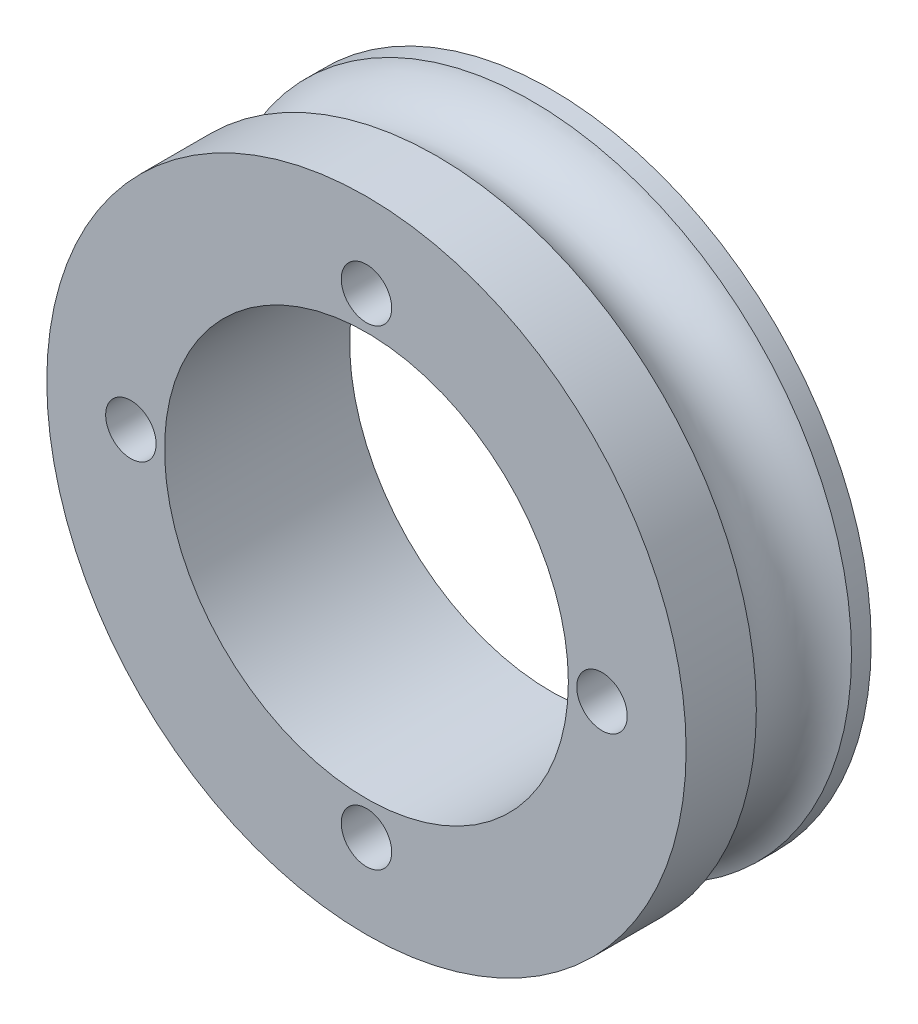
from build123d import *

# Parameters (mm, degrees)
SCHIZZO1_R                   = 19
SCHIZZO1_R_2                 = 12
SCHIZZO1_R_3                 = 1.5
ESTRUSIONE_ESTRUSIONE1_DEPTH = 11
SCHIZZO2_R                   = 3


with BuildPart() as part:
    # Schizzo1 → Estrusione-Estrusione1 (new body)
    with BuildSketch(Plane.XY):
        Circle(SCHIZZO1_R)
        Circle(SCHIZZO1_R_2, mode=Mode.SUBTRACT)
        with Locations((0, 14)):
            Circle(SCHIZZO1_R_3, mode=Mode.SUBTRACT)
        with Locations((14, 0)):
            Circle(SCHIZZO1_R_3, mode=Mode.SUBTRACT)
        with Locations((0, -14)):
            Circle(SCHIZZO1_R_3, mode=Mode.SUBTRACT)
        with Locations((-14, 0)):
            Circle(SCHIZZO1_R_3, mode=Mode.SUBTRACT)
    extrude(amount=ESTRUSIONE_ESTRUSIONE1_DEPTH)

    # Schizzo2 → Taglia-Rivoluzione1 (revolve, cut)
    with BuildSketch(Plane(origin=(0, 0, 0), x_dir=(0, 0, -1), z_dir=(1, 0, 0))):
        with Locations((-4, 20)):
            Circle(SCHIZZO2_R)
    revolve(axis=Axis((0, 0, 11), (0, 0, -1)), mode=Mode.SUBTRACT)


solid = part.part
